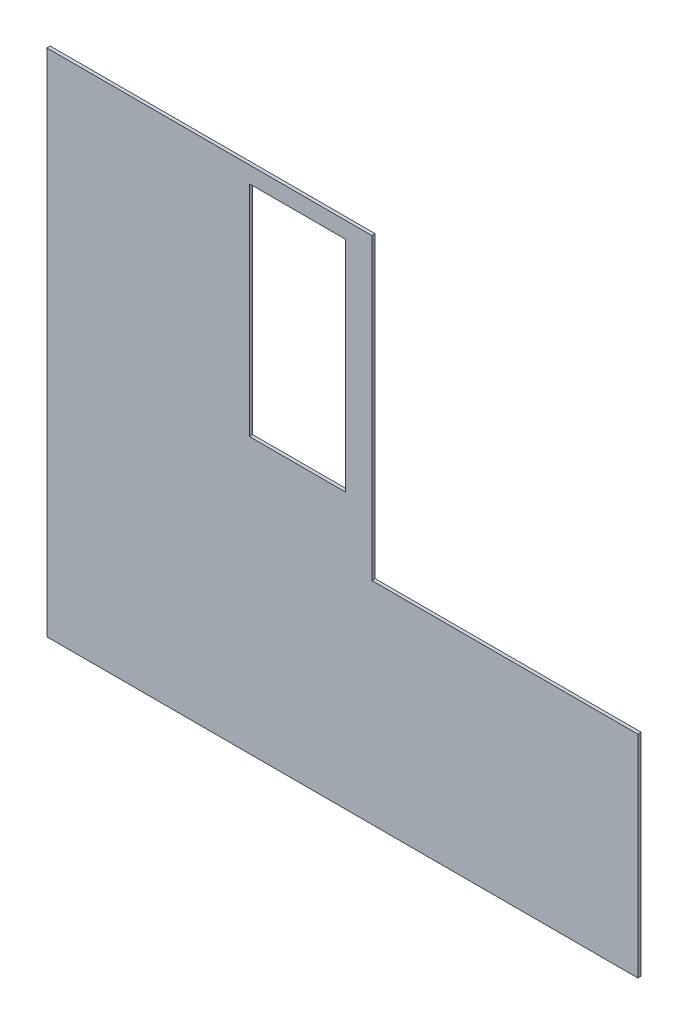
from build123d import *

# Parameters (mm, degrees)
ESQUISSE1_W        = 88
ESQUISSE1_H        = 200
BOSS_EXTRU_1_DEPTH = 3


with BuildPart() as part:
    # Esquisse1 → Boss.-Extru.1 (new body)
    with BuildSketch(Plane.XY):
        Polygon((589.223057321, -367.643778293), (49.223057321, -367.643778293), (49.223057321, 98.356221707), (346.223057321, 98.356221707), (346.223057321, -174.643778293), (589.223057321, -174.643778293), align=None)
        with Locations((278.223057321, -16.643778293)):
            Rectangle(ESQUISSE1_W, ESQUISSE1_H, mode=Mode.SUBTRACT)
    extrude(amount=BOSS_EXTRU_1_DEPTH)


solid = part.part
